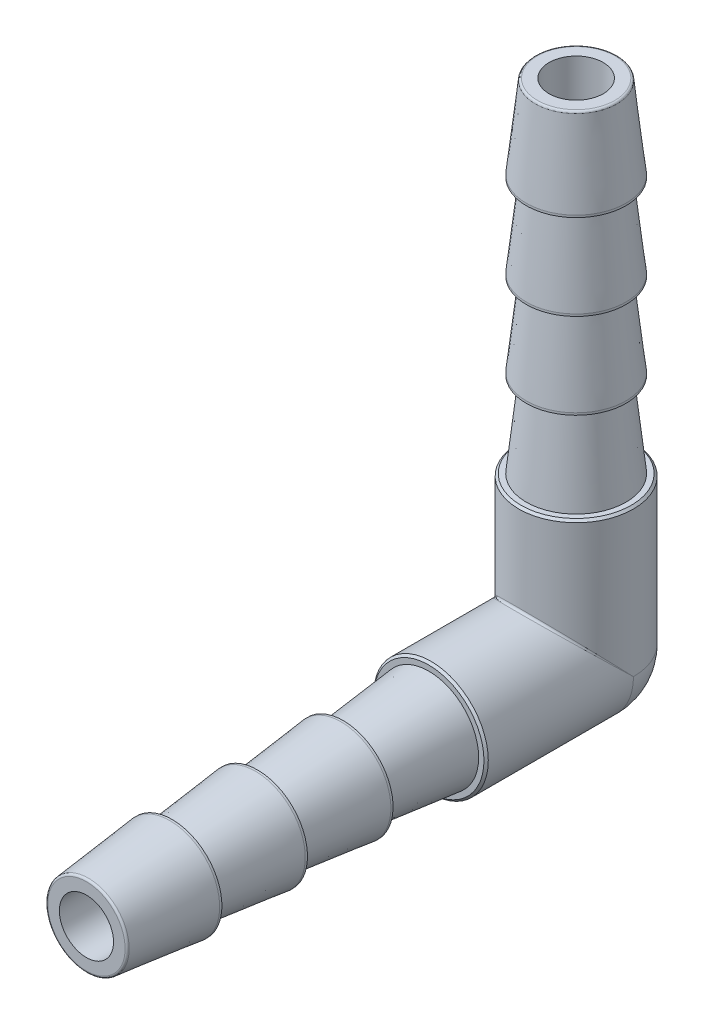
from build123d import *

# Parameters (mm, degrees)
LPATTERN1_COUNT              = 3
LPATTERN1_PITCH              = 5.0165
CHAMFER1_SIZE                = 0.127
CIRPATTERN1_COUNT            = 2
CIRPATTERN1_ANGLE            = 90
CHAMFER1_OF_CIRPATTERN1_SIZE = 0.127
CIRPATTERN2_COUNT            = 2
CIRPATTERN2_ANGLE            = 90
FILLET2_R                    = 0.127


with BuildPart() as part:
    # Sketch2 → Revolve1 (revolve)
    with BuildSketch(Plane(origin=(0, 0, 0), x_dir=(0, 0, -1), z_dir=(1, 0, 0)), mode=Mode.PRIVATE) as revolve1_sk:
        with BuildLine():
            Line((-28.702, 0), (-28.702, 3.35915))
            Line((-28.702, 3.35915), (0, 3.35915))
            ThreePointArc((0, 3.35915), (2.375277744, 2.375277744), (3.35915, 0))
            Line((3.35915, 0), (-28.702, 0))
        make_face()
    revolve1 = revolve(revolve1_sk.sketch.rotate(Axis((0, 0, 28.702), (0, 0, -1)), 90), axis=Axis((0, 0, 28.702), (0, 0, -1)))

    # Sketch3 → Cut-Revolve1 (revolve, cut)
    with BuildSketch(Plane(origin=(0, 0, 0), x_dir=(0, 0, -1), z_dir=(1, 0, 0)), mode=Mode.PRIVATE) as cut_revolve1_sk:
        Polygon((-28.702, 3.35915), (-28.702, 2.38125), (-13.6525, 2.38125), (-8.636, 2.921), (-8.636, 3.35915), align=None)
    cut_revolve1 = revolve(cut_revolve1_sk.sketch.rotate(Axis((0, 0, 28.702), (0, 0, -1)), 90), axis=Axis((0, 0, 28.702), (0, 0, -1)), mode=Mode.SUBTRACT)

    # Sketch4 → Revolve2 (revolve)
    with BuildSketch(Plane(origin=(0, 0, 0), x_dir=(0, 0, -1), z_dir=(1, 0, 0))):
        Polygon((-23.6855, 2.921), (-23.8125, 2.921), (-28.702, 2.38125), (-23.6855, 2.38125), align=None)
    revolve2 = revolve(axis=Axis((0, 0, 8.636), (0, 0, 1)))

    # LPattern1: Revolve2 ×3
    with Locations(*[(0, 0, -i * LPATTERN1_PITCH) for i in range(1, LPATTERN1_COUNT)]):
        add(revolve2)

    # Chamfer1
    chamfer1_edges = [part.edges().sort_by_distance(p)[0] for p in [
        (-3.35915, 0, 8.636),
    ]]
    chamfer(chamfer1_edges, length=CHAMFER1_SIZE)

    # CirPattern1: Revolve1, Cut-Revolve1, Revolve2 ×2 about axis
    cirpattern1_axis = Axis((-6.6671825, 0, 0), (-1, 0, 0))
    add([revolve1.rotate(cirpattern1_axis, i * CIRPATTERN1_ANGLE / (CIRPATTERN1_COUNT - 1)) for i in range(1, CIRPATTERN1_COUNT)])
    add([cut_revolve1.rotate(cirpattern1_axis, i * CIRPATTERN1_ANGLE / (CIRPATTERN1_COUNT - 1)) for i in range(1, CIRPATTERN1_COUNT)], mode=Mode.SUBTRACT)
    add([revolve2.rotate(cirpattern1_axis, i * CIRPATTERN1_ANGLE / (CIRPATTERN1_COUNT - 1)) for i in range(1, CIRPATTERN1_COUNT)])

    # CirPattern1 copy 1 sketch → CirPattern1 copy 1 (revolve)
    with BuildSketch(Plane(origin=(0, -5.0165, 0), x_dir=(0, -1, 0), z_dir=(1, 0, 0))):
        Polygon((-23.6855, 2.921), (-23.8125, 2.921), (-28.702, 2.38125), (-23.6855, 2.38125), align=None)
    revolve(axis=Axis((0, 3.6195, 0), (0, 1, 0)))

    # CirPattern1 copy 2 sketch → CirPattern1 copy 2 (revolve)
    with BuildSketch(Plane(origin=(0, -10.033, 0), x_dir=(0, -1, 0), z_dir=(1, 0, 0))):
        Polygon((-23.6855, 2.921), (-23.8125, 2.921), (-28.702, 2.38125), (-23.6855, 2.38125), align=None)
    revolve(axis=Axis((0, -1.397, 0), (0, 1, 0)))

    # Chamfer1 of CirPattern1
    chamfer1_of_cirpattern1_edges = [part.edges().sort_by_distance(p)[0] for p in [
        (-3.35915, 8.636, 0),
    ]]
    chamfer(chamfer1_of_cirpattern1_edges, length=CHAMFER1_OF_CIRPATTERN1_SIZE)

    # Sketch5 → Cut-Revolve2 (revolve, cut)
    with BuildSketch(Plane(origin=(0, 0, 0), x_dir=(0, 0, -1), z_dir=(1, 0, 0)), mode=Mode.PRIVATE) as cut_revolve2_sk:
        with BuildLine():
            Line((-28.702, 1.5875), (0, 1.5875))
            ThreePointArc((0, 1.5875), (1.122532015, 1.122532015), (1.5875, 0))
            Line((1.5875, 0), (-28.702, 0))
            Line((-28.702, 0), (-28.702, 1.5875))
        make_face()
    cut_revolve2 = revolve(cut_revolve2_sk.sketch.rotate(Axis((0, 0, 28.702), (0, 0, -1)), 270), axis=Axis((0, 0, 28.702), (0, 0, -1)), mode=Mode.SUBTRACT)

    # CirPattern2: Cut-Revolve2 ×2 about axis
    cirpattern2_axis = Axis((-6.6671825, 0, 0), (-1, 0, 0))
    for i in range(1, CIRPATTERN2_COUNT):
        add(cut_revolve2.rotate(cirpattern2_axis, i * CIRPATTERN2_ANGLE / (CIRPATTERN2_COUNT - 1)), mode=Mode.SUBTRACT)

    # Fillet2
    fillet2_edges = [part.edges().sort_by_distance(p)[0] for p in [
        (0, -2.38125, 28.702),
        (3.702e-06, 3.35915, 3.35915),
        (0, 28.702, 2.38125),
    ]]
    fillet(fillet2_edges, radius=FILLET2_R)


solid = part.part
